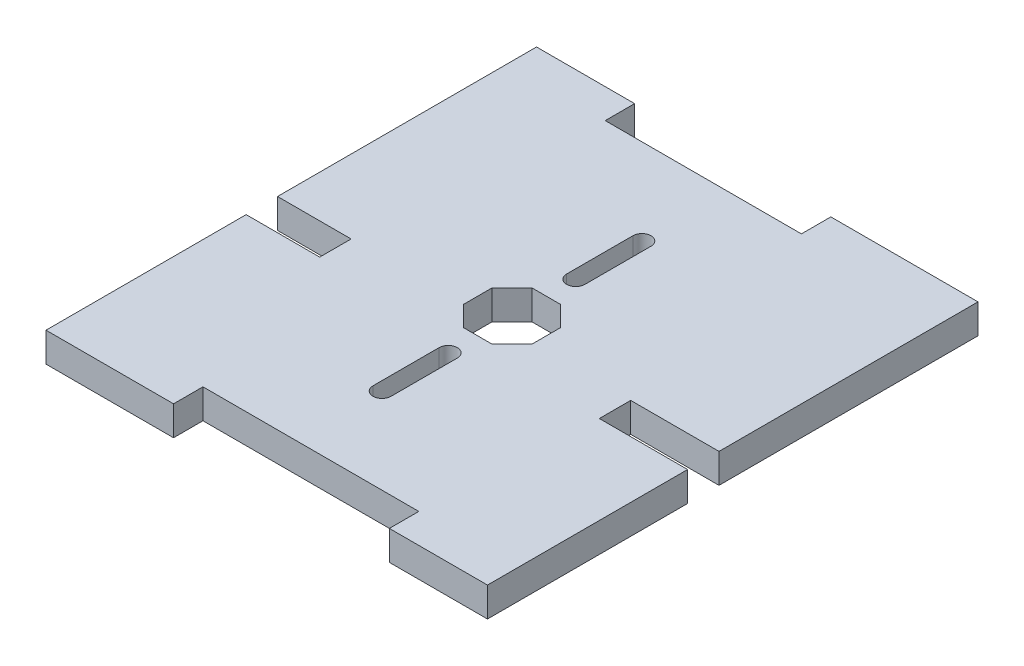
from build123d import *

# Parameters (mm, degrees)
SKETCH1_W           = 45
SKETCH1_H           = 50
BOSS_EXTRUDE1_DEPTH = 3
SKETCH2_W           = 20
SKETCH2_H           = 3
SKETCH2_W_2         = 22
SKETCH2_W_3         = 7.5
SKETCH2_W_4         = 9
CUT_EXTRUDE1_DEPTH  = 4
SKETCH4_W           = 7.5
SKETCH4_H           = 0.1
SKETCH4_W_2         = 9
CUT_EXTRUDE2_DEPTH  = 4


with BuildPart() as part:
    # Sketch1 → Boss-Extrude1 (new body)
    with BuildSketch(Plane(origin=(0, 0, 0), x_dir=(1, 0, 0), z_dir=(0, 1, 0))):
        with Locations((22.5, 25)):
            Rectangle(SKETCH1_W, SKETCH1_H)
    extrude(amount=BOSS_EXTRUDE1_DEPTH)

    # Sketch2 → Cut-Extrude1 (cut, through all)
    with BuildSketch(Plane(origin=(0, 3, 0), x_dir=(1, 0, 0), z_dir=(0, 1, 0))):
        with Locations((20, 48.5)):
            Rectangle(SKETCH2_W, SKETCH2_H)
        with Locations((24, 1.5)):
            Rectangle(SKETCH2_W_2, SKETCH2_H)
        with Locations((3.75, 22)):
            Rectangle(SKETCH2_W_3, SKETCH2_H)
        with Locations((40.5, 22)):
            Rectangle(SKETCH2_W_4, SKETCH2_H)
        Polygon((21.050252532, 21.5), (23.949747468, 21.5), (26, 23.550252532), (26, 26.449747468), (23.949747468, 28.5), (21.050252532, 28.5), (19, 26.449747468), (19, 23.550252532), align=None)
        with BuildLine():
            Line((21.575, 31.5), (21.575, 38.25))
            ThreePointArc((21.575, 38.25), (22.5, 39.175), (23.425, 38.25))
            Line((23.425, 38.25), (23.425, 31.5))
            ThreePointArc((23.425, 31.5), (22.5, 30.575), (21.575, 31.5))
        make_face()
        with BuildLine():
            Line((23.425, 18.5), (23.425, 11.75))
            ThreePointArc((23.425, 11.75), (22.5, 10.825), (21.575, 11.75))
            Line((21.575, 11.75), (21.575, 18.5))
            ThreePointArc((21.575, 18.5), (22.5, 19.425), (23.425, 18.5))
        make_face()
    extrude(amount=-CUT_EXTRUDE1_DEPTH, mode=Mode.SUBTRACT)

    # Sketch4 → Cut-Extrude2 (cut, through all)
    with BuildSketch(Plane(origin=(0, 3, 0), x_dir=(1, 0, 0), z_dir=(0, 1, 0))):
        with Locations((3.75, 23.55)):
            Rectangle(SKETCH4_W, SKETCH4_H)
        with Locations((3.75, 20.45)):
            Rectangle(SKETCH4_W, SKETCH4_H)
        with Locations((40.5, 20.45)):
            Rectangle(SKETCH4_W_2, SKETCH4_H)
        with Locations((40.5, 23.55)):
            Rectangle(SKETCH4_W_2, SKETCH4_H)
    extrude(amount=-CUT_EXTRUDE2_DEPTH, mode=Mode.SUBTRACT)


solid = part.part
